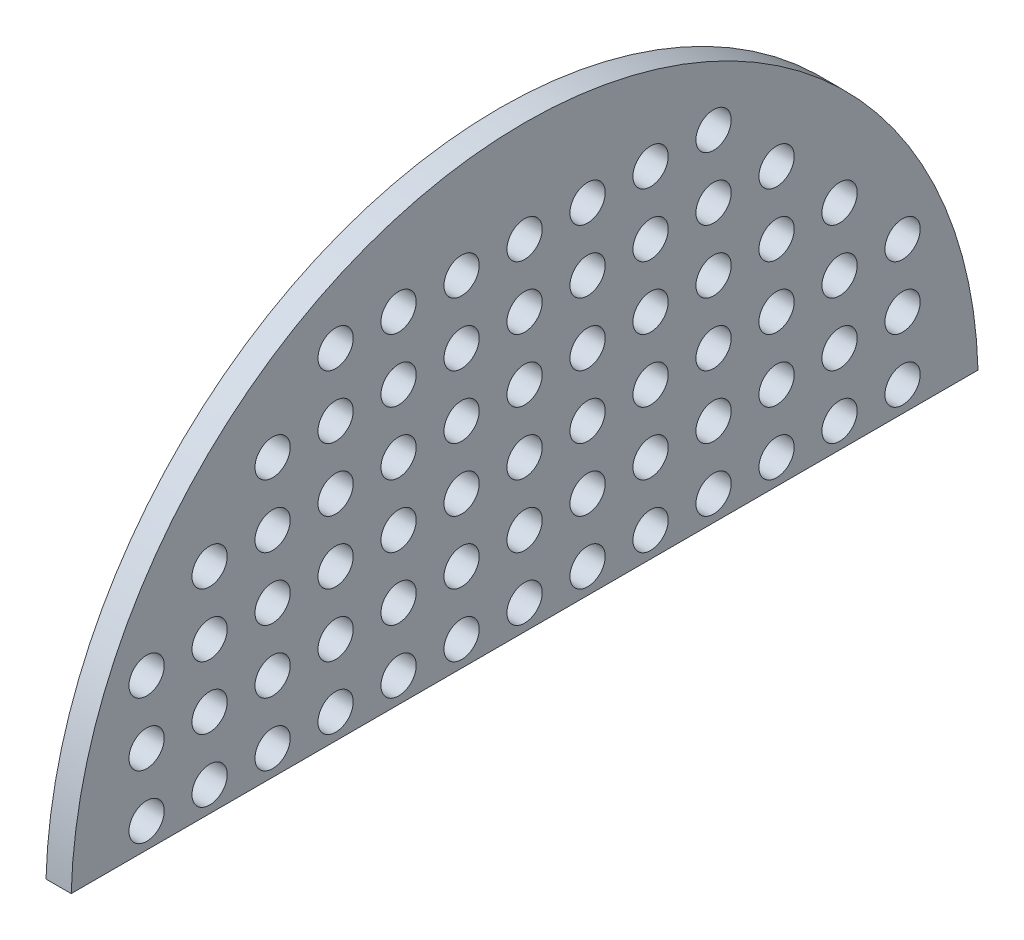
from build123d import *

# Parameters (mm, degrees)
SKETCH1_R           = 70
BOSS_EXTRUDE1_DEPTH = 100
SKETCH2_W           = 3655.38252847
SKETCH2_H           = 100
CUT_EXTRUDE1_DEPTH  = 101


with BuildPart() as part:
    # Sketch1 → Boss-Extrude1 (new body)
    with BuildSketch(Plane(origin=(0, 0, 0), x_dir=(0, 0, -1), z_dir=(1, 0, 0))):
        with BuildLine():
            Line((1800, 0), (-1800, 0))
            ThreePointArc((-1800, 0), (0, 1800), (1800, 0))
        make_face()
        with Locations((0, 150)):
            Circle(SKETCH1_R, mode=Mode.SUBTRACT)
        with Locations((250, 150)):
            Circle(SKETCH1_R, mode=Mode.SUBTRACT)
        with Locations((500, 150)):
            Circle(SKETCH1_R, mode=Mode.SUBTRACT)
        with Locations((750, 150)):
            Circle(SKETCH1_R, mode=Mode.SUBTRACT)
        with Locations((1000, 150)):
            Circle(SKETCH1_R, mode=Mode.SUBTRACT)
        with Locations((1250, 150)):
            Circle(SKETCH1_R, mode=Mode.SUBTRACT)
        with Locations((1500, 150)):
            Circle(SKETCH1_R, mode=Mode.SUBTRACT)
        with Locations((250, 400)):
            Circle(SKETCH1_R, mode=Mode.SUBTRACT)
        with Locations((500, 400)):
            Circle(SKETCH1_R, mode=Mode.SUBTRACT)
        with Locations((750, 400)):
            Circle(SKETCH1_R, mode=Mode.SUBTRACT)
        with Locations((1000, 400)):
            Circle(SKETCH1_R, mode=Mode.SUBTRACT)
        with Locations((1250, 400)):
            Circle(SKETCH1_R, mode=Mode.SUBTRACT)
        with Locations((1500, 400)):
            Circle(SKETCH1_R, mode=Mode.SUBTRACT)
        with Locations((250, 650)):
            Circle(SKETCH1_R, mode=Mode.SUBTRACT)
        with Locations((500, 650)):
            Circle(SKETCH1_R, mode=Mode.SUBTRACT)
        with Locations((750, 650)):
            Circle(SKETCH1_R, mode=Mode.SUBTRACT)
        with Locations((1000, 650)):
            Circle(SKETCH1_R, mode=Mode.SUBTRACT)
        with Locations((1250, 650)):
            Circle(SKETCH1_R, mode=Mode.SUBTRACT)
        with Locations((1500, 650)):
            Circle(SKETCH1_R, mode=Mode.SUBTRACT)
        with Locations((250, 900)):
            Circle(SKETCH1_R, mode=Mode.SUBTRACT)
        with Locations((500, 900)):
            Circle(SKETCH1_R, mode=Mode.SUBTRACT)
        with Locations((750, 900)):
            Circle(SKETCH1_R, mode=Mode.SUBTRACT)
        with Locations((1000, 900)):
            Circle(SKETCH1_R, mode=Mode.SUBTRACT)
        with Locations((1250, 900)):
            Circle(SKETCH1_R, mode=Mode.SUBTRACT)
        with Locations((250, 1150)):
            Circle(SKETCH1_R, mode=Mode.SUBTRACT)
        with Locations((500, 1150)):
            Circle(SKETCH1_R, mode=Mode.SUBTRACT)
        with Locations((750, 1150)):
            Circle(SKETCH1_R, mode=Mode.SUBTRACT)
        with Locations((1000, 1150)):
            Circle(SKETCH1_R, mode=Mode.SUBTRACT)
        with Locations((250, 1400)):
            Circle(SKETCH1_R, mode=Mode.SUBTRACT)
        with Locations((500, 1400)):
            Circle(SKETCH1_R, mode=Mode.SUBTRACT)
        with Locations((750, 1400)):
            Circle(SKETCH1_R, mode=Mode.SUBTRACT)
        with Locations((0, 400)):
            Circle(SKETCH1_R, mode=Mode.SUBTRACT)
        with Locations((0, 650)):
            Circle(SKETCH1_R, mode=Mode.SUBTRACT)
        with Locations((0, 900)):
            Circle(SKETCH1_R, mode=Mode.SUBTRACT)
        with Locations((0, 1150)):
            Circle(SKETCH1_R, mode=Mode.SUBTRACT)
        with Locations((0, 1400)):
            Circle(SKETCH1_R, mode=Mode.SUBTRACT)
        with Locations((-750, 1400)):
            Circle(SKETCH1_R, mode=Mode.SUBTRACT)
        with Locations((-500, 1400)):
            Circle(SKETCH1_R, mode=Mode.SUBTRACT)
        with Locations((-250, 1400)):
            Circle(SKETCH1_R, mode=Mode.SUBTRACT)
        with Locations((-1000, 1150)):
            Circle(SKETCH1_R, mode=Mode.SUBTRACT)
        with Locations((-750, 1150)):
            Circle(SKETCH1_R, mode=Mode.SUBTRACT)
        with Locations((-500, 1150)):
            Circle(SKETCH1_R, mode=Mode.SUBTRACT)
        with Locations((-250, 1150)):
            Circle(SKETCH1_R, mode=Mode.SUBTRACT)
        with Locations((-1250, 900)):
            Circle(SKETCH1_R, mode=Mode.SUBTRACT)
        with Locations((-1000, 900)):
            Circle(SKETCH1_R, mode=Mode.SUBTRACT)
        with Locations((-750, 900)):
            Circle(SKETCH1_R, mode=Mode.SUBTRACT)
        with Locations((-500, 900)):
            Circle(SKETCH1_R, mode=Mode.SUBTRACT)
        with Locations((-250, 900)):
            Circle(SKETCH1_R, mode=Mode.SUBTRACT)
        with Locations((-1500, 650)):
            Circle(SKETCH1_R, mode=Mode.SUBTRACT)
        with Locations((-1250, 650)):
            Circle(SKETCH1_R, mode=Mode.SUBTRACT)
        with Locations((-1000, 650)):
            Circle(SKETCH1_R, mode=Mode.SUBTRACT)
        with Locations((-750, 650)):
            Circle(SKETCH1_R, mode=Mode.SUBTRACT)
        with Locations((-500, 650)):
            Circle(SKETCH1_R, mode=Mode.SUBTRACT)
        with Locations((-250, 650)):
            Circle(SKETCH1_R, mode=Mode.SUBTRACT)
        with Locations((-1500, 400)):
            Circle(SKETCH1_R, mode=Mode.SUBTRACT)
        with Locations((-1250, 400)):
            Circle(SKETCH1_R, mode=Mode.SUBTRACT)
        with Locations((-1000, 400)):
            Circle(SKETCH1_R, mode=Mode.SUBTRACT)
        with Locations((-750, 400)):
            Circle(SKETCH1_R, mode=Mode.SUBTRACT)
        with Locations((-500, 400)):
            Circle(SKETCH1_R, mode=Mode.SUBTRACT)
        with Locations((-250, 400)):
            Circle(SKETCH1_R, mode=Mode.SUBTRACT)
        with Locations((-1500, 150)):
            Circle(SKETCH1_R, mode=Mode.SUBTRACT)
        with Locations((-1250, 150)):
            Circle(SKETCH1_R, mode=Mode.SUBTRACT)
        with Locations((-1000, 150)):
            Circle(SKETCH1_R, mode=Mode.SUBTRACT)
        with Locations((-750, 150)):
            Circle(SKETCH1_R, mode=Mode.SUBTRACT)
        with Locations((-500, 150)):
            Circle(SKETCH1_R, mode=Mode.SUBTRACT)
        with Locations((-250, 150)):
            Circle(SKETCH1_R, mode=Mode.SUBTRACT)
    extrude(amount=BOSS_EXTRUDE1_DEPTH)

    # Sketch2 → Cut-Extrude1 (cut, through all)
    with BuildSketch(Plane(origin=(100, 0, 0), x_dir=(0, 0, -1), z_dir=(1, 0, 0))):
        Rectangle(SKETCH2_W, SKETCH2_H)
    extrude(amount=-CUT_EXTRUDE1_DEPTH, mode=Mode.SUBTRACT)


solid = part.part
